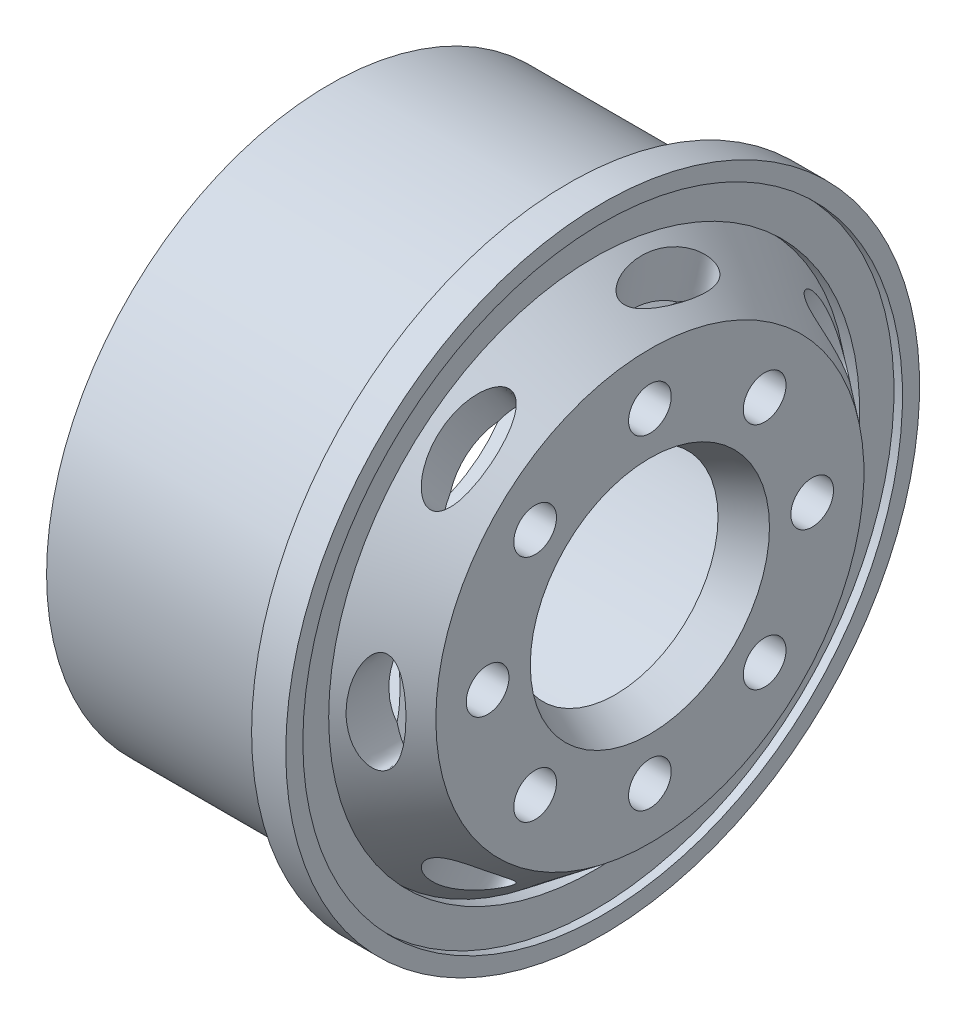
from build123d import *

# Parameters (mm, degrees)
SKETCH2_R          = 1.25
CUT_EXTRUDE1_DEPTH = 19.762750464
SKETCH3_RX         = 3
SKETCH3_RY         = 1
CUT_EXTRUDE2_DEPTH = 3
CIRPATTERN1_COUNT  = 7


with BuildPart() as part:
    # Sketch1 → Revolve1 (revolve)
    with BuildSketch(Plane(origin=(0, 0, 0), x_dir=(1, 0, 0), z_dir=(0, 1, 0))):
        Polygon((5.686305636, 15.537968137), (4.955330367, 15.537968137), (8.9490561, 12.528479936), (8.9490561, 7), (6.936305636, 6), (6.936305636, 11.540924884), (2.943128086, 14.55), (-9.813694364, 14.55), (-9.813694364, 16.55), (4.186305636, 16.55), (4.186305636, 18.55), (5.686305636, 18.55), (6.186305636, 18.55), (6.186305636, 17.55), (5.686305636, 17.55), align=None)
    revolve(axis=Axis((-37.278866169, 0, 0), (1, 0, 0)))

    # Sketch2 → Cut-Extrude1 (cut, through all)
    with BuildSketch(Plane(origin=(8.9490561, 0, 0), x_dir=(0, 0, -1), z_dir=(1, 0, 0))):
        with Locations((0, 9.5)):
            Circle(SKETCH2_R)
        with Locations((6.717514421, 6.717514421)):
            Circle(SKETCH2_R)
        with Locations((9.5, 0)):
            Circle(SKETCH2_R)
        with Locations((6.717514421, -6.717514421)):
            Circle(SKETCH2_R)
        with Locations((0, -9.5)):
            Circle(SKETCH2_R)
        with Locations((-6.717514421, -6.717514421)):
            Circle(SKETCH2_R)
        with Locations((-9.5, 0)):
            Circle(SKETCH2_R)
        with Locations((-6.717514421, 6.717514421)):
            Circle(SKETCH2_R)
    extrude(amount=-CUT_EXTRUDE1_DEPTH, mode=Mode.SUBTRACT)

    # Sketch3 → Cut-Extrude2 (cut)
    with BuildSketch(Plane.XY.offset(15)):
        with Locations(Location((6.952193234, 0), (0, 0, -90))):
            Ellipse(SKETCH3_RX, SKETCH3_RY)
    cut_extrude2 = extrude(amount=-CUT_EXTRUDE2_DEPTH, mode=Mode.SUBTRACT)

    # CirPattern1: Cut-Extrude2 ×7 about axis
    cirpattern1_axis = Axis((8.9490561, 0, 0), (-1, 0, 0))
    for i in range(1, CIRPATTERN1_COUNT):
        add(cut_extrude2.rotate(cirpattern1_axis, i * 360 / CIRPATTERN1_COUNT), mode=Mode.SUBTRACT)


solid = part.part
